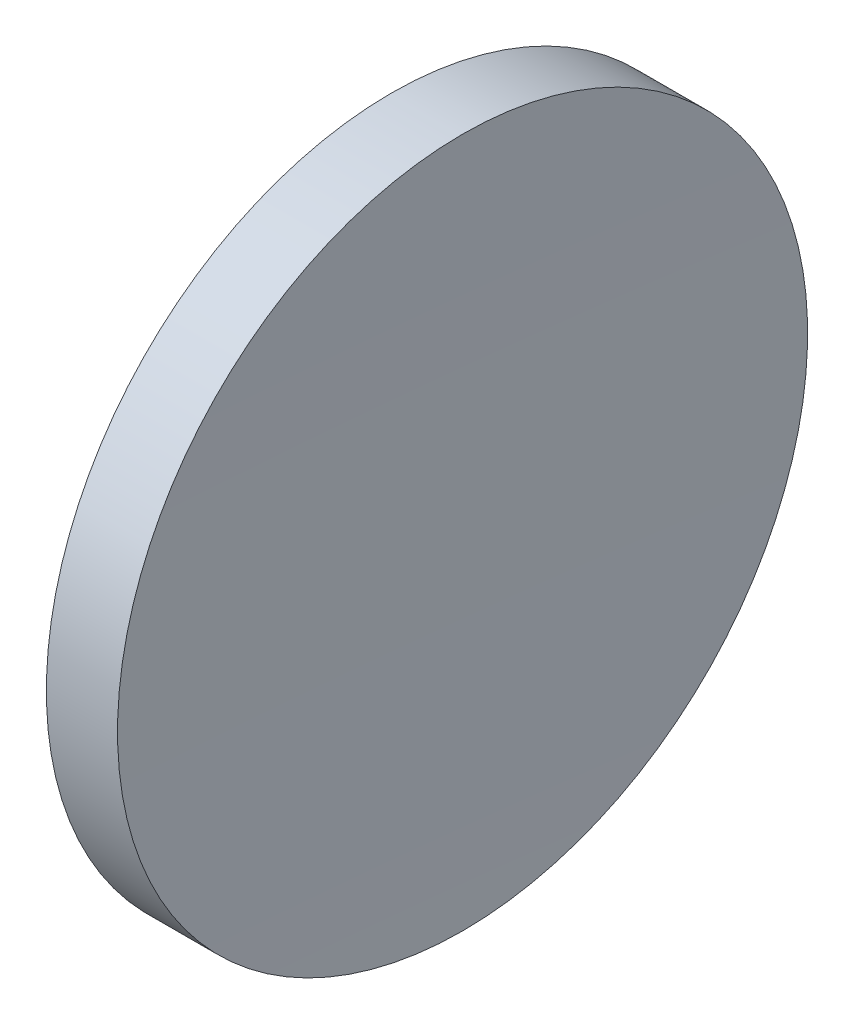
from build123d import *


with BuildPart() as part:
    # 草图1 → 旋转1 (revolve)
    with BuildSketch(Plane.XY):
        with BuildLine():
            Line((122.959684254, 77.716840471), (125.538011592, 77.716840471))
            ThreePointArc((125.538011592, 77.716840471), (125.443648965, 71.467157066), (125.412193694, 65.216840471))
            Line((125.412193694, 65.216840471), (122.612193699, 65.216840471))
            ThreePointArc((122.612193699, 65.216840471), (122.699083115, 71.469254998), (122.959684254, 77.716840471))
        make_face()
    revolve(axis=Axis((115.944491298, 65.216840471, 0), (1, 0, 0)))


solid = part.part
